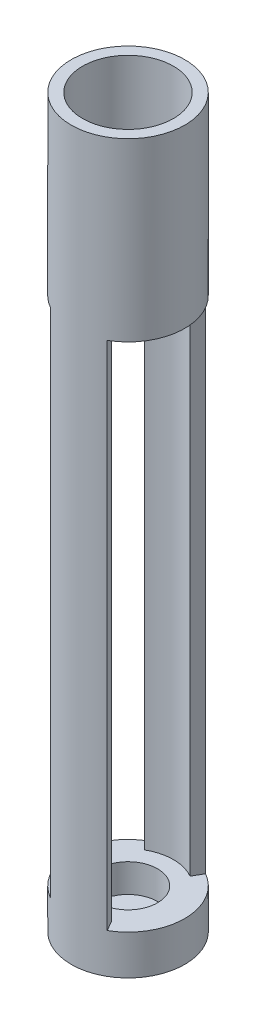
from build123d import *

# Parameters (mm, degrees)
SKETCH1_R            = 5
BOSS_EXTRUDE1_DEPTH  = 3.5
SKETCH2_R            = 2.6
CUT_EXTRUDE1_DEPTH   = 2.5
BOSS_EXTRUDE2_DEPTH  = 45
SKETCH14_R           = 5
SKETCH14_R_2         = 1.3
BOSS_EXTRUDE8_DEPTH  = 3
SKETCH15_R           = 5
SKETCH15_R_2         = 2.6
BOSS_EXTRUDE9_DEPTH  = 2.5
SKETCH7_R            = 1
CUT_EXTRUDE2_DEPTH   = 2
CIRPATTERN1_COUNT    = 6
CUT_EXTRUDE3_START   = -3.5
SKETCH12_R           = 0.2
CUT_EXTRUDE3_DEPTH   = 4.5
CIRPATTERN2_COUNT    = 6
SKETCH16_R           = 5
SKETCH16_R_2         = 4
BOSS_EXTRUDE10_DEPTH = 10


with BuildPart() as part:
    # Sketch1 → Boss-Extrude1 (new body)
    with BuildSketch(Plane(origin=(0, 0, 0), x_dir=(1, 0, 0), z_dir=(0, 1, 0))):
        Circle(SKETCH1_R)
    extrude(amount=BOSS_EXTRUDE1_DEPTH)

    # Sketch2 → Cut-Extrude1 (cut)
    with BuildSketch(Plane(origin=(0, 3.5, 0), x_dir=(1, 0, 0), z_dir=(0, 1, 0))):
        Circle(SKETCH2_R)
    extrude(amount=-CUT_EXTRUDE1_DEPTH, mode=Mode.SUBTRACT)

    # Sketch3 → Boss-Extrude2 (add)
    with BuildSketch(Plane(origin=(0, 3.5, 0), x_dir=(1, 0, 0), z_dir=(0, 1, 0))):
        with BuildLine():
            ThreePointArc((-2.5, -4.330127019), (0, -5), (2.5, -4.330127019))
            Line((2.5, -4.330127019), (2, -3.464101615))
            ThreePointArc((2, -3.464101615), (0, -4), (-2, -3.464101615))
            Line((-2, -3.464101615), (-2.5, -4.330127019))
        make_face()
        with BuildLine():
            ThreePointArc((2.5, 4.330127019), (0, 5), (-2.5, 4.330127019))
            Line((-2.5, 4.330127019), (-2, 3.464101615))
            ThreePointArc((-2, 3.464101615), (0, 4), (2, 3.464101615))
            Line((2, 3.464101615), (2.5, 4.330127019))
        make_face()
    extrude(amount=BOSS_EXTRUDE2_DEPTH)

    # Sketch14 → Boss-Extrude8 (add)
    with BuildSketch(Plane(origin=(0, 48.5, 0), x_dir=(1, 0, 0), z_dir=(0, 1, 0))):
        Circle(SKETCH14_R)
        Circle(SKETCH14_R_2, mode=Mode.SUBTRACT)
    extrude(amount=BOSS_EXTRUDE8_DEPTH)

    # Sketch15 → Boss-Extrude9 (add)
    with BuildSketch(Plane(origin=(0, 51.5, 0), x_dir=(1, 0, 0), z_dir=(0, 1, 0))):
        Circle(SKETCH15_R)
        Circle(SKETCH15_R_2, mode=Mode.SUBTRACT)
    extrude(amount=BOSS_EXTRUDE9_DEPTH)

    # Sketch7 → Cut-Extrude2 (cut)
    with BuildSketch(Plane.XZ.offset(-48.5)):
        with Locations((0, 2.5)):
            Circle(SKETCH7_R)
    cut_extrude2 = extrude(amount=-CUT_EXTRUDE2_DEPTH, mode=Mode.SUBTRACT)

    # CirPattern1: Cut-Extrude2 ×6 about axis
    cirpattern1_axis = Axis((0, 0, 0), (0, 1, 0))
    for i in range(1, CIRPATTERN1_COUNT):
        add(cut_extrude2.rotate(cirpattern1_axis, i * 360 / CIRPATTERN1_COUNT), mode=Mode.SUBTRACT)

    # Sketch12 → Cut-Extrude3 (cut)
    with BuildSketch(Plane(origin=(0, 54, 0), x_dir=(1, 0, 0), z_dir=(0, 1, 0)).offset(CUT_EXTRUDE3_START)):
        with Locations((0, -3)):
            Circle(SKETCH12_R)
    cut_extrude3 = extrude(amount=CUT_EXTRUDE3_DEPTH, mode=Mode.SUBTRACT)

    # CirPattern2: Cut-Extrude3 ×6 about axis
    cirpattern2_axis = Axis((0, 0, 0), (0, 1, 0))
    for i in range(1, CIRPATTERN2_COUNT):
        add(cut_extrude3.rotate(cirpattern2_axis, i * 360 / CIRPATTERN2_COUNT), mode=Mode.SUBTRACT)

    # Sketch16 → Boss-Extrude10 (add)
    with BuildSketch(Plane(origin=(0, 54, 0), x_dir=(1, 0, 0), z_dir=(0, 1, 0))):
        Circle(SKETCH16_R)
        Circle(SKETCH16_R_2, mode=Mode.SUBTRACT)
    extrude(amount=BOSS_EXTRUDE10_DEPTH)


solid = part.part
